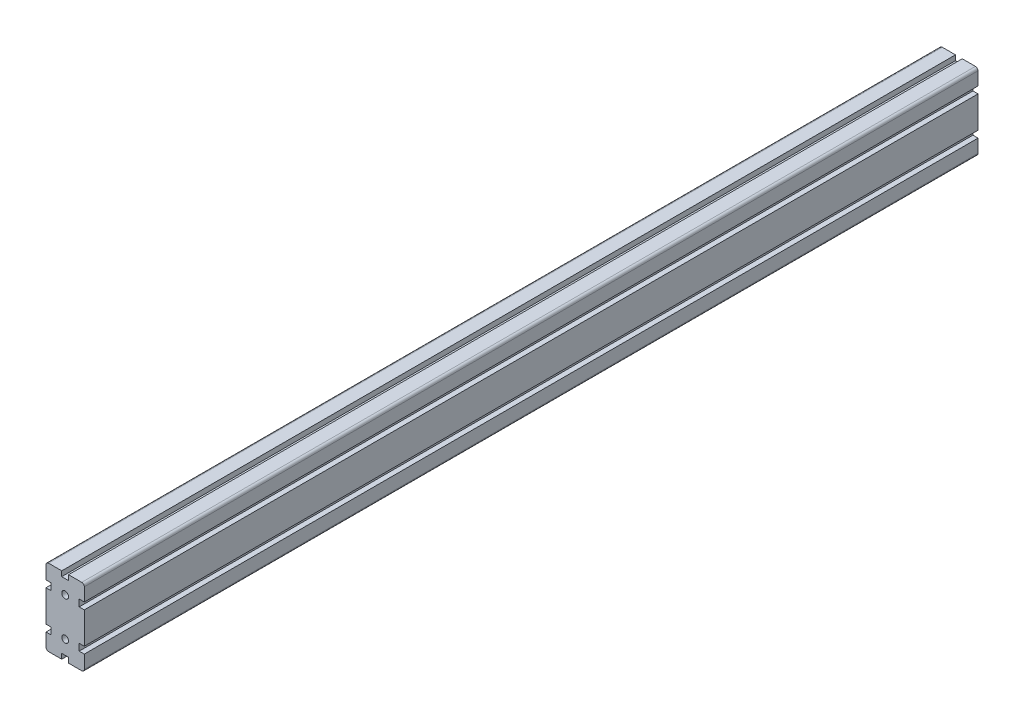
from build123d import *

# Parameters (mm, degrees)
ESQUISSE1_R        = 4
BOSS_EXTRU_1_DEPTH = 1050


with BuildPart() as part:
    # Esquisse1 → Boss.-Extru.1 (new body)
    with BuildSketch(Plane(origin=(0, 0, -1000), x_dir=(-1, 0, 0), z_dir=(0, 0, -1))):
        with BuildLine():
            Line((16.5, 26.5), (22.5, 26.5))
            Line((22.5, 26.5), (22.5, 42))
            ThreePointArc((22.5, 42), (21.621320344, 44.121320344), (19.5, 45))
            Line((19.5, 45), (4, 45))
            Line((4, 45), (4, 39))
            Line((4, 39), (-4, 39))
            Line((-4, 39), (-4, 45))
            Line((-4, 45), (-19.5, 45))
            ThreePointArc((-19.5, 45), (-21.621320344, 44.121320344), (-22.5, 42))
            Line((-22.5, 42), (-22.5, 26.5))
            Line((-22.5, 26.5), (-16.5, 26.5))
            Line((-16.5, 26.5), (-16.5, 18.5))
            Line((-16.5, 18.5), (-22.5, 18.5))
            Line((-22.5, 18.5), (-22.5, -18.5))
            Line((-22.5, -18.5), (-16.5, -18.5))
            Line((-16.5, -18.5), (-16.5, -26.5))
            Line((-16.5, -26.5), (-22.5, -26.5))
            Line((-22.5, -26.5), (-22.5, -42))
            ThreePointArc((-22.5, -42), (-21.621320344, -44.121320344), (-19.5, -45))
            Line((-19.5, -45), (-4, -45))
            Line((-4, -45), (-4, -39))
            Line((-4, -39), (4, -39))
            Line((4, -39), (4, -45))
            Line((4, -45), (19.5, -45))
            ThreePointArc((19.5, -45), (21.621320344, -44.121320344), (22.5, -42))
            Line((22.5, -42), (22.5, -26.5))
            Line((22.5, -26.5), (16.5, -26.5))
            Line((16.5, -26.5), (16.5, -18.5))
            Line((16.5, -18.5), (22.5, -18.5))
            Line((22.5, -18.5), (22.5, 18.5))
            Line((22.5, 18.5), (16.5, 18.5))
            Line((16.5, 18.5), (16.5, 26.5))
        make_face()
        with Locations((0, 22.5)):
            Circle(ESQUISSE1_R, mode=Mode.SUBTRACT)
        with Locations((0, -22.5)):
            Circle(ESQUISSE1_R, mode=Mode.SUBTRACT)
    extrude(amount=-BOSS_EXTRU_1_DEPTH)


solid = part.part
